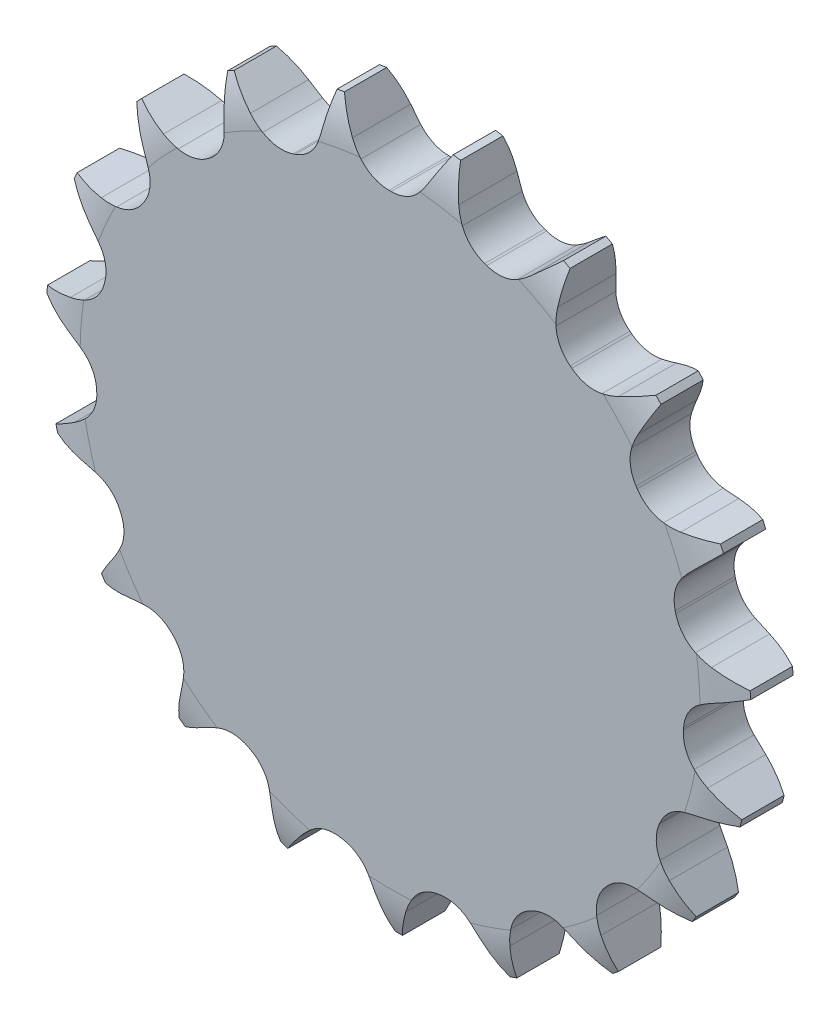
from build123d import *

# Parameters (mm, degrees)
ODEBRAT_VYSUNUT_M1_DEPTH = 7.975
KRUHOV_POLE1_COUNT       = 19


with BuildPart() as part:
    # Skica1 → Rotovat2 (revolve)
    with BuildSketch(Plane(origin=(0, 0, 0), x_dir=(0, 0, -1), z_dir=(1, 0, 0)), mode=Mode.PRIVATE) as rotovat2_sk:
        with BuildLine():
            Line((0, 0), (0, 36.128781396))
            ThreePointArc((0, 36.128781396), (-0.257904332, 38.682281347), (-1.0212, 41.132639763))
            Line((-1.0212, 41.132639763), (-5.9538, 41.132639763))
            ThreePointArc((-5.9538, 41.132639763), (-6.717095668, 38.682281347), (-6.975, 36.128781396))
            Line((-6.975, 36.128781396), (-6.975, 0))
            Line((-6.975, 0), (0, 0))
        make_face()
    revolve(rotovat2_sk.sketch.rotate(Axis((0, 0, 0), (0, 0, 1)), 90), axis=Axis((0, 0, 0), (0, 0, 1)))  # turned: the seam where the file's is

    # Skica2 → Odebrat vysunutím1 (cut, through all)
    with BuildSketch(Plane.XY):
        with BuildLine():
            Line((4.476742665, 37.405259763), (7.412916045, 42.490861237))
            ThreePointArc((7.412916045, 42.490861237), (0, 43.132639763), (-7.412916045, 42.490861237))
            Line((-7.412916045, 42.490861237), (-4.476742665, 37.405259763))
            ThreePointArc((-4.476742665, 37.405259763), (-3.969695666, 36.607757712), (-3.396435236, 35.856439763))
            ThreePointArc((-3.396435236, 35.856439763), (-1.932243612, 34.726573387), (-0.127, 34.324639763))
            Line((-0.127, 34.324639763), (0.127, 34.324639763))
            ThreePointArc((0.127, 34.324639763), (1.932243612, 34.726573387), (3.396435236, 35.856439763))
            ThreePointArc((3.396435236, 35.856439763), (3.969695666, 36.607757712), (4.476742665, 37.405259763))
        make_face()
    odebrat_vysunut_m1 = extrude(amount=ODEBRAT_VYSUNUT_M1_DEPTH, mode=Mode.SUBTRACT)

    # Kruhové pole1: Odebrat vysunutím1 ×19 about axis
    kruhov_pole1_axis = Axis((0, 0, 0), (0, 0, 1))
    for i in range(1, KRUHOV_POLE1_COUNT):
        add(odebrat_vysunut_m1.rotate(kruhov_pole1_axis, i * 360 / KRUHOV_POLE1_COUNT), mode=Mode.SUBTRACT)


solid = part.part
